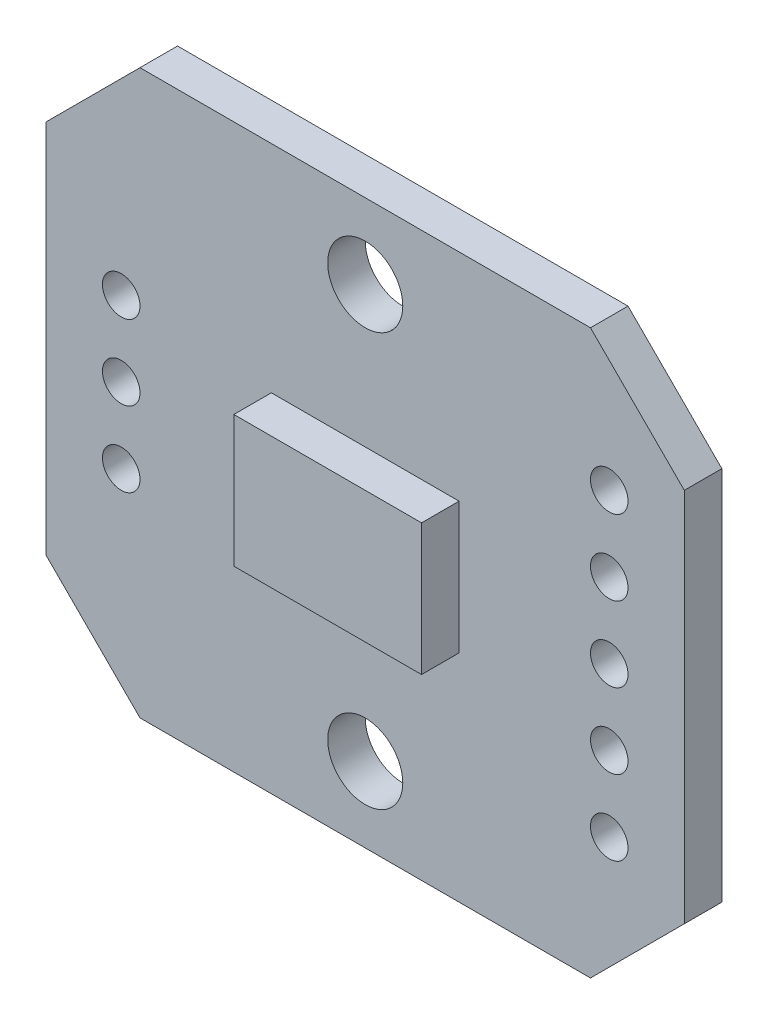
from build123d import *

# Parameters (mm, degrees)
SKETCH1_W           = 17
SKETCH1_H           = 15
BOSS_EXTRUDE1_DEPTH = 1
CHAMFER1_SIZE       = 2.5
BOSS_EXTRUDE2_START = 1
SKETCH2_W           = 5
SKETCH2_H           = 3.5
BOSS_EXTRUDE2_DEPTH = 1
SKETCH3_R           = 1
SKETCH3_R_2         = 0.5
CUT_EXTRUDE1_DEPTH  = 1
SKETCH4_W           = 2
SKETCH4_H           = 1.2
SKETCH4_W_2         = 0.5
SKETCH4_W_3         = 1.5
SKETCH4_H_2         = 0.8
BOSS_EXTRUDE3_DEPTH = 0.5
SKETCH5_W           = 3
SKETCH5_H           = 1.5
CUT_EXTRUDE2_DEPTH  = 0.01


with BuildPart() as part:
    # Sketch1 → Boss-Extrude1 (new body)
    with BuildSketch(Plane.XY):
        Rectangle(SKETCH1_W, SKETCH1_H)
    extrude(amount=BOSS_EXTRUDE1_DEPTH)

    # Chamfer1
    chamfer1_edges = [part.edges().sort_by_distance(p)[0] for p in [
        (8.5, -7.5, 0.5),
        (-8.5, -7.5, 0.5),
        (-8.5, 7.5, 0.5),
        (8.5, 7.5, 0.5),
    ]]
    chamfer(chamfer1_edges, length=CHAMFER1_SIZE)

    # Sketch2 → Boss-Extrude2 (add)
    with BuildSketch(Plane.XY.offset(BOSS_EXTRUDE2_START)):
        Rectangle(SKETCH2_W, SKETCH2_H)
    extrude(amount=BOSS_EXTRUDE2_DEPTH)

    # Sketch3 → Cut-Extrude1 (cut)
    with BuildSketch(Plane.XY):
        with Locations((0, 5.5)):
            Circle(SKETCH3_R)
        with Locations((0, -5.5)):
            Circle(SKETCH3_R)
        with Locations((6.5, 0)):
            Circle(SKETCH3_R_2)
        with Locations((-6.5, 0)):
            Circle(SKETCH3_R_2)
        with Locations((6.5, 2)):
            Circle(SKETCH3_R_2)
        with Locations((6.5, 4)):
            Circle(SKETCH3_R_2)
        with Locations((-6.5, 2)):
            Circle(SKETCH3_R_2)
        with Locations((-6.5, -2)):
            Circle(SKETCH3_R_2)
        with Locations((6.5, -4)):
            Circle(SKETCH3_R_2)
        with Locations((6.5, -2)):
            Circle(SKETCH3_R_2)
    extrude(amount=CUT_EXTRUDE1_DEPTH, mode=Mode.SUBTRACT)

    # Sketch4 → Boss-Extrude3 (add)
    with BuildSketch(Plane.XY):
        with Locations((-0.618205111, -2.566679178)):
            Rectangle(SKETCH4_W, SKETCH4_H)
        with Locations((-2.420773885, -4.883367435)):
            Rectangle(SKETCH4_W_2, SKETCH4_H)
        with Locations((3.286986257, -4.838471609)):
            Rectangle(SKETCH4_W_3, SKETCH4_H_2)
    extrude(amount=-BOSS_EXTRUDE3_DEPTH)

    # Sketch5 → Cut-Extrude2 (cut)
    with BuildSketch(Plane.XY):
        with Locations((6.5, -4)):
            Rectangle(SKETCH5_W, SKETCH5_H)
        with Locations((6.5, -2)):
            Rectangle(SKETCH5_W, SKETCH5_H)
        with Locations((6.5, 0)):
            Rectangle(SKETCH5_W, SKETCH5_H)
        with Locations((6.5, 2)):
            Rectangle(SKETCH5_W, SKETCH5_H)
        with Locations((6.5, 4)):
            Rectangle(SKETCH5_W, SKETCH5_H)
        with Locations((-6.5, -2)):
            Rectangle(SKETCH5_W, SKETCH5_H)
        with Locations((-6.5, 0)):
            Rectangle(SKETCH5_W, SKETCH5_H)
        with Locations((-6.5, 2)):
            Rectangle(SKETCH5_W, SKETCH5_H)
    extrude(amount=CUT_EXTRUDE2_DEPTH, mode=Mode.SUBTRACT)


solid = part.part
